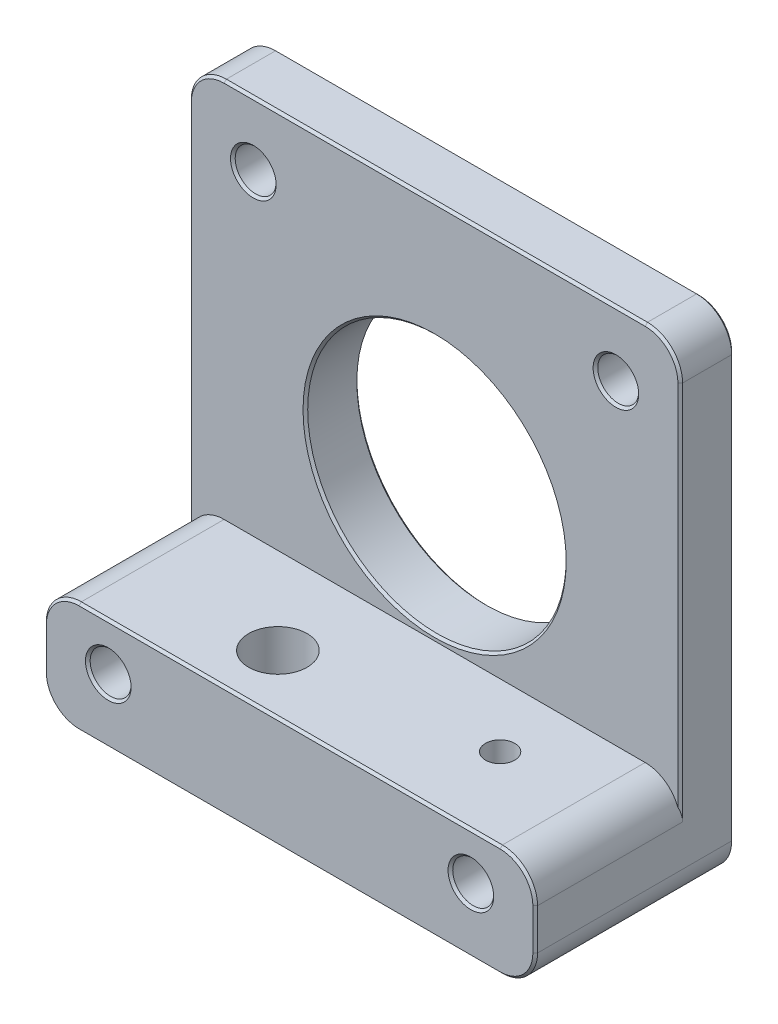
from build123d import *

# Parameters (mm, degrees)
SKETCH_1_W          = 42
SKETCH_1_H          = 42
EXTRUDE_1_DEPTH     = 17
SKETCH_2_W          = 42
SKETCH_2_H          = 32.5
CUT_EXTRUDE_1_DEPTH = 12.4
SKETCH_3_R          = 11.05
CUT_EXTRUDE_2_DEPTH = 12.4
SKETCH_4_R          = 2.5
CUT_EXTRUDE_3_DEPTH = 12.4
SKETCH_5_R          = 1.25
CUT_EXTRUDE_4_DEPTH = 12.4
FILLET_1_R          = 3
CHAMFER_1_SIZE      = 0.2
CHAMFER_2_SIZE      = 0.2
CHAMFER_3_SIZE      = 0.2
SKETCH_6_R          = 1.75
CUT_EXTRUDE_5_DEPTH = 26
CHAMFER_4_SIZE      = 0.2


with BuildPart() as part:
    # Эскиз1 → Бобышка-Вытянуть1 (new body)
    with BuildSketch(Plane.XY):
        with Locations((21, 21)):
            Rectangle(SKETCH_1_W, SKETCH_1_H)
    extrude(amount=EXTRUDE_1_DEPTH)

    # Эскиз2 → Вырез-Вытянуть1 (cut)
    with BuildSketch(Plane.XY.offset(17)):
        with Locations((21, 25.75)):
            Rectangle(SKETCH_2_W, SKETCH_2_H)
    extrude(amount=-CUT_EXTRUDE_1_DEPTH, mode=Mode.SUBTRACT)

    # Эскиз3 → Вырез-Вытянуть2 (cut)
    with BuildSketch(Plane(origin=(0, 0, 0), x_dir=(-1, 0, 0), z_dir=(0, 0, -1))):
        with Locations((-21, 21)):
            Circle(SKETCH_3_R)
    extrude(amount=-CUT_EXTRUDE_2_DEPTH, mode=Mode.SUBTRACT)

    # Эскиз4 → Вырез-Вытянуть3 (cut)
    with BuildSketch(Plane(origin=(0, 9.5, 0), x_dir=(1, 0, 0), z_dir=(0, 1, 0))):
        with Locations((15, -12)):
            Circle(SKETCH_4_R)
    extrude(amount=-CUT_EXTRUDE_3_DEPTH, mode=Mode.SUBTRACT)

    # Эскиз5 → Вырез-Вытянуть4 (cut)
    with BuildSketch(Plane(origin=(0, 9.5, 0), x_dir=(1, 0, 0), z_dir=(0, 1, 0))):
        with Locations((32, -10)):
            Circle(SKETCH_5_R)
    extrude(amount=-CUT_EXTRUDE_4_DEPTH, mode=Mode.SUBTRACT)

    # Скругление1
    fillet_1_edges = [part.edges().sort_by_distance(p)[0] for p in [
        (0, 42, 2.3),
        (42, 42, 2.3),
        (0, 9.5, 10.8),
        (42, 9.5, 10.8),
        (42, 0, 8.5),
        (0, 0, 8.5),
    ]]
    fillet(fillet_1_edges, radius=FILLET_1_R)

    # Фаска1
    chamfer_1_edges = [part.edges().sort_by_distance(p)[0] for p in [
        (32.05, 21, 0),
        (21, 42, 0),
        (0, 21, 0),
        (42, 21, 0),
        (21, 0, 0),
        (0.878679656, 0.878679656, 0),
        (41.121320344, 0.878679656, 0),
        (0.878679656, 41.121320344, 0),
        (41.121320344, 41.121320344, 0),
    ]]
    chamfer(chamfer_1_edges, length=CHAMFER_1_SIZE)

    # Фаска2
    chamfer_2_edges = [part.edges().sort_by_distance(p)[0] for p in [
        (42, 24.25, 4.6),
        (21, 42, 4.6),
        (42, 4.75, 17),
        (0, 24.25, 4.6),
        (0.878679656, 41.121320344, 4.6),
        (41.121320344, 41.121320344, 4.6),
        (0, 4.75, 17),
        (21, 0, 17),
        (21, 9.5, 17),
        (0.878679656, 8.621320344, 17),
        (0.878679656, 0.878679656, 17),
        (41.121320344, 8.621320344, 17),
        (41.121320344, 0.878679656, 17),
    ]]
    chamfer(chamfer_2_edges, length=CHAMFER_2_SIZE)

    # Фаска3
    chamfer_3_edges = [part.edges().sort_by_distance(p)[0] for p in [
        (32.05, 21, 4.6),
    ]]
    chamfer(chamfer_3_edges, length=CHAMFER_3_SIZE)

    # Эскиз6 → Вырез-Вытянуть5 (cut)
    with BuildSketch(Plane(origin=(0, 0, 0), x_dir=(-1, 0, 0), z_dir=(0, 0, -1))):
        with Locations((-5.5, 36.5)):
            Circle(SKETCH_6_R)
        with Locations((-36.5, 36.5)):
            Circle(SKETCH_6_R)
        with Locations((-5.5, 5.5)):
            Circle(SKETCH_6_R)
        with Locations((-36.5, 5.5)):
            Circle(SKETCH_6_R)
    extrude(amount=-CUT_EXTRUDE_5_DEPTH, mode=Mode.SUBTRACT)

    # Фаска4
    chamfer_4_edges = [part.edges().sort_by_distance(p)[0] for p in [
        (7.25, 36.5, 4.6),
        (7.25, 36.5, 0),
        (38.25, 36.5, 4.6),
        (38.25, 36.5, 0),
        (7.25, 5.5, 17),
        (7.25, 5.5, 0),
        (38.25, 5.5, 17),
        (38.25, 5.5, 0),
    ]]
    chamfer(chamfer_4_edges, length=CHAMFER_4_SIZE)


solid = part.part
